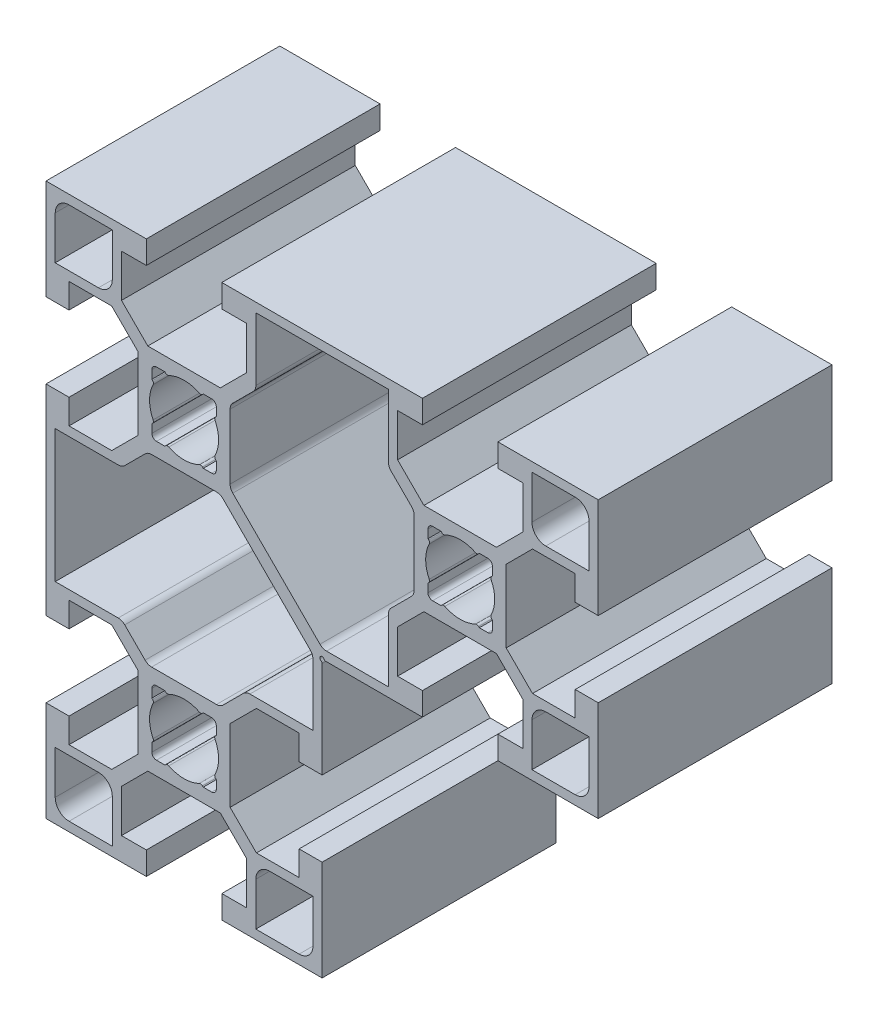
from build123d import *

# Parameters (mm, degrees)
EXTRUSION4_DEPTH = 25.4


with BuildPart() as part:
    # Sketch1 → Extrusion4 (new body)
    with BuildSketch(Plane.XY):
        with BuildLine():
            Line((-15.000000008, 14.999999985), (-4.099998488, 14.999999985))
            Line((-4.099998488, 14.999999985), (-4.099998488, 12.499999985))
            Line((-4.099998488, 12.499999985), (-6.799995438, 12.499999985))
            Line((-6.799995438, 12.499999985), (-6.799995438, 7.860655585))
            Line((-6.799995438, 7.860655585), (-3.939339838, 4.999999985))
            Line((-3.939339838, 4.999999985), (3.939339802, 4.999999985))
            Line((3.939339802, 4.999999985), (6.799995402, 7.860655585))
            Line((6.799995402, 7.860655585), (6.799995402, 12.499999985))
            Line((6.799995402, 12.499999985), (4.099998452, 12.499999985))
            Line((4.099998452, 12.499999985), (4.099998452, 14.999999985))
            Line((4.099998452, 14.999999985), (25.900001512, 14.999999985))
            Line((25.900001512, 14.999999985), (25.900001512, 12.499999985))
            Line((25.900001512, 12.499999985), (23.200004562, 12.499999985))
            Line((23.200004562, 12.499999985), (23.200004562, 7.860655585))
            Line((23.200004562, 7.860655585), (26.060660162, 4.999999985))
            Line((26.060660162, 4.999999985), (33.939339802, 4.999999985))
            Line((33.939339802, 4.999999985), (36.799995402, 7.860655585))
            Line((36.799995402, 7.860655585), (36.799995402, 12.499999985))
            Line((36.799995402, 12.499999985), (34.099998452, 12.499999985))
            Line((34.099998452, 12.499999985), (34.099998452, 14.999999985))
            Line((34.099998452, 14.999999985), (44.999999972, 14.999999985))
            Line((44.999999972, 14.999999985), (44.999999972, 4.099998475))
            Line((44.999999972, 4.099998475), (42.499999972, 4.099998475))
            Line((42.499999972, 4.099998475), (42.499999972, 6.799995425))
            Line((42.499999972, 6.799995425), (37.860655572, 6.799995425))
            Line((37.860655572, 6.799995425), (34.999999972, 3.939339825))
            Line((34.999999972, 3.939339825), (34.999999972, -3.939339815))
            Line((34.999999972, -3.939339815), (37.860655572, -6.799995415))
            Line((37.860655572, -6.799995415), (42.499999972, -6.799995415))
            Line((42.499999972, -6.799995415), (42.499999972, -4.099998465))
            Line((42.499999972, -4.099998465), (44.999999972, -4.099998465))
            Line((44.999999972, -4.099998465), (44.999999972, -14.999999985))
            Line((44.999999972, -14.999999985), (34.099998452, -14.999999985))
            Line((34.099998452, -14.999999985), (34.099998452, -12.499999985))
            Line((34.099998452, -12.499999985), (36.799995402, -12.499999985))
            Line((36.799995402, -12.499999985), (36.799995402, -7.860655585))
            Line((36.799995402, -7.860655585), (33.939339802, -4.999999985))
            Line((33.939339802, -4.999999985), (26.060660162, -4.999999985))
            Line((26.060660162, -4.999999985), (23.200004562, -7.860655585))
            Line((23.200004562, -7.860655585), (23.200004562, -12.499999985))
            Line((23.200004562, -12.499999985), (25.900001512, -12.499999985))
            Line((25.900001512, -12.499999985), (25.900001512, -14.999999985))
            Line((25.900001512, -14.999999985), (15.403112862, -14.999999985))
            ThreePointArc((15.403112862, -14.999999985), (15.297703605, -14.969967307), (15.223951582, -14.888888875))
            ThreePointArc((15.223951582, -14.888888875), (14.823223282, -14.823223295), (14.888888862, -15.223951595))
            ThreePointArc((14.888888862, -15.223951595), (14.96996729, -15.297703621), (14.999999972, -15.403112875))
            Line((14.999999972, -15.403112875), (14.999999972, -25.900001525))
            Line((14.999999972, -25.900001525), (12.499999972, -25.900001525))
            Line((12.499999972, -25.900001525), (12.499999972, -23.200004575))
            Line((12.499999972, -23.200004575), (7.860655572, -23.200004575))
            Line((7.860655572, -23.200004575), (4.999999972, -26.060660175))
            Line((4.999999972, -26.060660175), (4.999999972, -33.939339815))
            Line((4.999999972, -33.939339815), (7.860655572, -36.799995415))
            Line((7.860655572, -36.799995415), (12.499999972, -36.799995415))
            Line((12.499999972, -36.799995415), (12.499999972, -34.099998465))
            Line((12.499999972, -34.099998465), (14.999999972, -34.099998465))
            Line((14.999999972, -34.099998465), (14.999999972, -44.999999985))
            Line((14.999999972, -44.999999985), (4.099998452, -44.999999985))
            Line((4.099998452, -44.999999985), (4.099998452, -42.499999985))
            Line((4.099998452, -42.499999985), (6.799995402, -42.499999985))
            Line((6.799995402, -42.499999985), (6.799995402, -37.860655585))
            Line((6.799995402, -37.860655585), (3.939339802, -34.999999985))
            Line((3.939339802, -34.999999985), (-3.939339838, -34.999999985))
            Line((-3.939339838, -34.999999985), (-6.799995438, -37.860655585))
            Line((-6.799995438, -37.860655585), (-6.799995438, -42.499999985))
            Line((-6.799995438, -42.499999985), (-4.099998488, -42.499999985))
            Line((-4.099998488, -42.499999985), (-4.099998488, -44.999999985))
            Line((-4.099998488, -44.999999985), (-15.000000008, -44.999999985))
            Line((-15.000000008, -44.999999985), (-15.000000008, -34.099998465))
            Line((-15.000000008, -34.099998465), (-12.500000008, -34.099998465))
            Line((-12.500000008, -34.099998465), (-12.500000008, -36.799995415))
            Line((-12.500000008, -36.799995415), (-7.860655608, -36.799995415))
            Line((-7.860655608, -36.799995415), (-5.000000008, -33.939339815))
            Line((-5.000000008, -33.939339815), (-5.000000008, -26.060660175))
            Line((-5.000000008, -26.060660175), (-7.860655608, -23.200004575))
            Line((-7.860655608, -23.200004575), (-12.500000008, -23.200004575))
            Line((-12.500000008, -23.200004575), (-12.500000008, -25.900001525))
            Line((-12.500000008, -25.900001525), (-15.000000008, -25.900001525))
            Line((-15.000000008, -25.900001525), (-15.000000008, -4.099998475))
            Line((-15.000000008, -4.099998475), (-12.500000008, -4.099998475))
            Line((-12.500000008, -4.099998475), (-12.500000008, -6.799995425))
            Line((-12.500000008, -6.799995425), (-7.860655608, -6.799995425))
            Line((-7.860655608, -6.799995425), (-5.000000008, -3.939339825))
            Line((-5.000000008, -3.939339825), (-5.000000008, 3.939339815))
            Line((-5.000000008, 3.939339815), (-7.860655608, 6.799995415))
            Line((-7.860655608, 6.799995415), (-12.500000008, 6.799995415))
            Line((-12.500000008, 6.799995415), (-12.500000008, 4.099998465))
            Line((-12.500000008, 4.099998465), (-15.000000008, 4.099998465))
            Line((-15.000000008, 4.099998465), (-15.000000008, 14.999999985))
        make_face()
        with BuildLine():
            Line((-7.800000008, -39.300000005), (-7.800000008, -44.000004575))
            Line((-7.800000008, -44.000004575), (-12.500004578, -44.000004575))
            ThreePointArc((-12.500004578, -44.000004575), (-13.560664748, -43.560664745), (-14.000004578, -42.500004575))
            Line((-14.000004578, -42.500004575), (-14.000004578, -37.800000005))
            Line((-14.000004578, -37.800000005), (-9.300000008, -37.800000005))
            ThreePointArc((-9.300000008, -37.800000005), (-8.239339838, -38.239339835), (-7.800000008, -39.300000005))
        make_face(mode=Mode.SUBTRACT)
        with BuildLine():
            Line((43.999999992, 12.499999995), (43.999999992, 7.799995425))
            Line((43.999999992, 7.799995425), (39.299995422, 7.799995425))
            ThreePointArc((39.299995422, 7.799995425), (38.239335252, 8.239335255), (37.799995422, 9.299995425))
            Line((37.799995422, 9.299995425), (37.799995422, 13.999999995))
            Line((37.799995422, 13.999999995), (42.499999992, 13.999999995))
            ThreePointArc((42.499999992, 13.999999995), (43.560660162, 13.560660165), (43.999999992, 12.499999995))
        make_face(mode=Mode.SUBTRACT)
        with BuildLine():
            Line((9.299999992, -37.800000005), (14.000004562, -37.800000005))
            Line((14.000004562, -37.800000005), (14.000004562, -42.500004575))
            ThreePointArc((14.000004562, -42.500004575), (13.560664732, -43.560664745), (12.500004562, -44.000004575))
            Line((12.500004562, -44.000004575), (7.799999992, -44.000004575))
            Line((7.799999992, -44.000004575), (7.799999992, -39.300000005))
            ThreePointArc((7.799999992, -39.300000005), (8.239339822, -38.239339835), (9.299999992, -37.800000005))
        make_face(mode=Mode.SUBTRACT)
        with BuildLine():
            Line((39.299999992, -7.800000005), (44.000004562, -7.800000005))
            Line((44.000004562, -7.800000005), (44.000004562, -12.500004575))
            ThreePointArc((44.000004562, -12.500004575), (43.560664732, -13.560664745), (42.500004562, -14.000004575))
            Line((42.500004562, -14.000004575), (37.799999992, -14.000004575))
            Line((37.799999992, -14.000004575), (37.799999992, -9.300000005))
            ThreePointArc((37.799999992, -9.300000005), (38.239339822, -8.239339835), (39.299999992, -7.800000005))
        make_face(mode=Mode.SUBTRACT)
        with BuildLine():
            Line((-12.500000008, 13.999999995), (-7.799995438, 13.999999995))
            Line((-7.799995438, 13.999999995), (-7.799995438, 9.299995425))
            ThreePointArc((-7.799995438, 9.299995425), (-8.239335268, 8.239335255), (-9.299995438, 7.799995425))
            Line((-9.299995438, 7.799995425), (-14.000000008, 7.799995425))
            Line((-14.000000008, 7.799995425), (-14.000000008, 12.499999995))
            ThreePointArc((-14.000000008, 12.499999995), (-13.560660178, 13.560660165), (-12.500000008, 13.999999995))
        make_face(mode=Mode.SUBTRACT)
        with BuildLine():
            Line((32.005133972, 3.419347545), (32.085786412, 3.499999985))
            Line((32.085786412, 3.499999985), (32.999999972, 3.499999985))
            ThreePointArc((32.999999972, 3.499999985), (33.353553362, 3.353553375), (33.499999972, 2.999999985))
            Line((33.499999972, 2.999999985), (33.499999972, 2.085786425))
            Line((33.499999972, 2.085786425), (33.419347532, 2.005133985))
            ThreePointArc((33.419347532, 2.005133985), (33.335474922, 1.841799984), (33.362481082, 1.660186995))
            ThreePointArc((33.362481082, 1.660186995), (33.749999978, -1e-09), (33.362481082, -1.660186995))
            ThreePointArc((33.362481082, -1.660186995), (33.335474922, -1.841799984), (33.419347532, -2.005133985))
            Line((33.419347532, -2.005133985), (33.499999972, -2.085786425))
            Line((33.499999972, -2.085786425), (33.499999972, -2.999999985))
            ThreePointArc((33.499999972, -2.999999985), (33.353553362, -3.353553375), (32.999999972, -3.499999985))
            Line((32.999999972, -3.499999985), (32.085786412, -3.499999985))
            Line((32.085786412, -3.499999985), (32.005133972, -3.419347545))
            ThreePointArc((32.005133972, -3.419347545), (31.841799971, -3.335474935), (31.660186982, -3.362481095))
            ThreePointArc((31.660186982, -3.362481095), (29.999999987, -3.749999998), (28.339812992, -3.362481095))
            ThreePointArc((28.339812992, -3.362481095), (28.158200003, -3.335474935), (27.994866002, -3.419347545))
            Line((27.994866002, -3.419347545), (27.914213562, -3.499999985))
            Line((27.914213562, -3.499999985), (27.000000002, -3.499999985))
            ThreePointArc((27.000000002, -3.499999985), (26.646446612, -3.353553375), (26.500000002, -2.999999985))
            Line((26.500000002, -2.999999985), (26.500000002, -2.085786425))
            Line((26.500000002, -2.085786425), (26.580652442, -2.005133985))
            ThreePointArc((26.580652442, -2.005133985), (26.664525052, -1.841799984), (26.637518892, -1.660186995))
            ThreePointArc((26.637518892, -1.660186995), (26.249999985, -1e-09), (26.637518892, 1.660186995))
            ThreePointArc((26.637518892, 1.660186995), (26.664525052, 1.841799984), (26.580652442, 2.005133985))
            Line((26.580652442, 2.005133985), (26.500000002, 2.085786425))
            Line((26.500000002, 2.085786425), (26.500000002, 2.999999985))
            ThreePointArc((26.500000002, 2.999999985), (26.646446612, 3.353553375), (27.000000002, 3.499999985))
            Line((27.000000002, 3.499999985), (27.914213562, 3.499999985))
            Line((27.914213562, 3.499999985), (27.994866002, 3.419347545))
            ThreePointArc((27.994866002, 3.419347545), (28.158200003, 3.335474935), (28.339812992, 3.362481095))
            ThreePointArc((28.339812992, 3.362481095), (29.999999987, 3.749999995), (31.660186982, 3.362481095))
            ThreePointArc((31.660186982, 3.362481095), (31.841799971, 3.335474935), (32.005133972, 3.419347545))
        make_face(mode=Mode.SUBTRACT)
        with BuildLine():
            Line((2.005133972, -26.580652455), (2.085786412, -26.500000015))
            Line((2.085786412, -26.500000015), (2.999999972, -26.500000015))
            ThreePointArc((2.999999972, -26.500000015), (3.353553362, -26.646446625), (3.499999972, -27.000000015))
            Line((3.499999972, -27.000000015), (3.499999972, -27.914213575))
            Line((3.499999972, -27.914213575), (3.419347532, -27.994866015))
            ThreePointArc((3.419347532, -27.994866015), (3.335474922, -28.158200016), (3.362481082, -28.339813005))
            ThreePointArc((3.362481082, -28.339813005), (3.749999978, -30.000000001), (3.362481082, -31.660186995))
            ThreePointArc((3.362481082, -31.660186995), (3.335474922, -31.841799984), (3.419347532, -32.005133985))
            Line((3.419347532, -32.005133985), (3.499999972, -32.085786425))
            Line((3.499999972, -32.085786425), (3.499999972, -32.999999985))
            ThreePointArc((3.499999972, -32.999999985), (3.353553362, -33.353553375), (2.999999972, -33.499999985))
            Line((2.999999972, -33.499999985), (2.085786412, -33.499999985))
            Line((2.085786412, -33.499999985), (2.005133972, -33.419347545))
            ThreePointArc((2.005133972, -33.419347545), (1.841799971, -33.335474935), (1.660186982, -33.362481095))
            ThreePointArc((1.660186982, -33.362481095), (-1.3e-08, -33.749999998), (-1.660187008, -33.362481095))
            ThreePointArc((-1.660187008, -33.362481095), (-1.841799997, -33.335474935), (-2.005133998, -33.419347545))
            Line((-2.005133998, -33.419347545), (-2.085786438, -33.499999985))
            Line((-2.085786438, -33.499999985), (-2.999999998, -33.499999985))
            ThreePointArc((-2.999999998, -33.499999985), (-3.353553388, -33.353553375), (-3.499999998, -32.999999985))
            Line((-3.499999998, -32.999999985), (-3.499999998, -32.085786425))
            Line((-3.499999998, -32.085786425), (-3.419347558, -32.005133985))
            ThreePointArc((-3.419347558, -32.005133985), (-3.335474948, -31.841799984), (-3.362481108, -31.660186995))
            ThreePointArc((-3.362481108, -31.660186995), (-3.750000015, -30.000000001), (-3.362481108, -28.339813005))
            ThreePointArc((-3.362481108, -28.339813005), (-3.335474948, -28.158200016), (-3.419347558, -27.994866015))
            Line((-3.419347558, -27.994866015), (-3.499999998, -27.914213575))
            Line((-3.499999998, -27.914213575), (-3.499999998, -27.000000015))
            ThreePointArc((-3.499999998, -27.000000015), (-3.353553388, -26.646446625), (-2.999999998, -26.500000015))
            Line((-2.999999998, -26.500000015), (-2.085786438, -26.500000015))
            Line((-2.085786438, -26.500000015), (-2.005133998, -26.580652455))
            ThreePointArc((-2.005133998, -26.580652455), (-1.841799997, -26.664525065), (-1.660187008, -26.637518905))
            ThreePointArc((-1.660187008, -26.637518905), (-1.3e-08, -26.250000005), (1.660186982, -26.637518905))
            ThreePointArc((1.660186982, -26.637518905), (1.841799971, -26.664525065), (2.005133972, -26.580652455))
        make_face(mode=Mode.SUBTRACT)
        with BuildLine():
            Line((2.005133972, 3.419347545), (2.085786412, 3.499999985))
            Line((2.085786412, 3.499999985), (2.999999972, 3.499999985))
            ThreePointArc((2.999999972, 3.499999985), (3.353553362, 3.353553375), (3.499999972, 2.999999985))
            Line((3.499999972, 2.999999985), (3.499999972, 2.085786425))
            Line((3.499999972, 2.085786425), (3.419347532, 2.005133985))
            ThreePointArc((3.419347532, 2.005133985), (3.335474922, 1.841799984), (3.362481082, 1.660186995))
            ThreePointArc((3.362481082, 1.660186995), (3.749999978, -1e-09), (3.362481082, -1.660186995))
            ThreePointArc((3.362481082, -1.660186995), (3.335474922, -1.841799984), (3.419347532, -2.005133985))
            Line((3.419347532, -2.005133985), (3.499999972, -2.085786425))
            Line((3.499999972, -2.085786425), (3.499999972, -2.999999985))
            ThreePointArc((3.499999972, -2.999999985), (3.353553362, -3.353553375), (2.999999972, -3.499999985))
            Line((2.999999972, -3.499999985), (2.085786412, -3.499999985))
            Line((2.085786412, -3.499999985), (2.005133972, -3.419347545))
            ThreePointArc((2.005133972, -3.419347545), (1.841799971, -3.335474935), (1.660186982, -3.362481095))
            ThreePointArc((1.660186982, -3.362481095), (-1.3e-08, -3.749999998), (-1.660187008, -3.362481095))
            ThreePointArc((-1.660187008, -3.362481095), (-1.841799997, -3.335474935), (-2.005133998, -3.419347545))
            Line((-2.005133998, -3.419347545), (-2.085786438, -3.499999985))
            Line((-2.085786438, -3.499999985), (-2.999999998, -3.499999985))
            ThreePointArc((-2.999999998, -3.499999985), (-3.353553388, -3.353553375), (-3.499999998, -2.999999985))
            Line((-3.499999998, -2.999999985), (-3.499999998, -2.085786425))
            Line((-3.499999998, -2.085786425), (-3.419347558, -2.005133985))
            ThreePointArc((-3.419347558, -2.005133985), (-3.335474948, -1.841799984), (-3.362481108, -1.660186995))
            ThreePointArc((-3.362481108, -1.660186995), (-3.750000015, -1e-09), (-3.362481108, 1.660186995))
            ThreePointArc((-3.362481108, 1.660186995), (-3.335474948, 1.841799984), (-3.419347558, 2.005133985))
            Line((-3.419347558, 2.005133985), (-3.499999998, 2.085786425))
            Line((-3.499999998, 2.085786425), (-3.499999998, 2.999999985))
            ThreePointArc((-3.499999998, 2.999999985), (-3.353553388, 3.353553375), (-2.999999998, 3.499999985))
            Line((-2.999999998, 3.499999985), (-2.085786438, 3.499999985))
            Line((-2.085786438, 3.499999985), (-2.005133998, 3.419347545))
            ThreePointArc((-2.005133998, 3.419347545), (-1.841799997, 3.335474935), (-1.660187008, 3.362481095))
            ThreePointArc((-1.660187008, 3.362481095), (-1.3e-08, 3.749999995), (1.660186982, 3.362481095))
            ThreePointArc((1.660186982, 3.362481095), (1.841799971, 3.335474935), (2.005133972, 3.419347545))
        make_face(mode=Mode.SUBTRACT)
        with BuildLine():
            Line((-3.525126258, -4.999999995), (3.525126252, -4.999999995))
            ThreePointArc((3.525126252, -4.999999995), (3.907809683, -5.076120465), (4.232233032, -5.292893215))
            Line((4.232233032, -5.292893215), (13.707106762, -14.767766945))
            ThreePointArc((13.707106762, -14.767766945), (13.923879512, -15.092190294), (13.999999982, -15.474873725))
            Line((13.999999982, -15.474873725), (13.999999982, -22.200004585))
            Line((13.999999982, -22.200004585), (7.153548802, -22.200004585))
            ThreePointArc((7.153548802, -22.200004585), (6.770865371, -22.276125055), (6.446442022, -22.492897805))
            Line((6.446442022, -22.492897805), (4.232233032, -24.707106795))
            ThreePointArc((4.232233032, -24.707106795), (3.907809683, -24.923879545), (3.525126252, -25.000000015))
            Line((3.525126252, -25.000000015), (-3.525126258, -25.000000015))
            ThreePointArc((-3.525126258, -25.000000015), (-3.907809689, -24.923879545), (-4.232233038, -24.707106795))
            Line((-4.232233038, -24.707106795), (-6.446442028, -22.492897805))
            ThreePointArc((-6.446442028, -22.492897805), (-6.770865377, -22.276125055), (-7.153548808, -22.200004585))
            Line((-7.153548808, -22.200004585), (-13.999999988, -22.200004585))
            Line((-13.999999988, -22.200004585), (-13.999999988, -7.799995425))
            Line((-13.999999988, -7.799995425), (-7.153548808, -7.799995425))
            ThreePointArc((-7.153548808, -7.799995425), (-6.770865377, -7.723874955), (-6.446442028, -7.507102205))
            Line((-6.446442028, -7.507102205), (-4.232233038, -5.292893215))
            ThreePointArc((-4.232233038, -5.292893215), (-3.907809689, -5.076120465), (-3.525126258, -4.999999995))
        make_face(mode=Mode.SUBTRACT)
        with BuildLine():
            Line((5.292893202, 4.232233025), (7.507102192, 6.446442015))
            ThreePointArc((7.507102192, 6.446442015), (7.723874942, 6.770865364), (7.799995412, 7.153548795))
            Line((7.799995412, 7.153548795), (7.799995412, 13.999999975))
            Line((7.799995412, 13.999999975), (22.200004572, 13.999999975))
            Line((22.200004572, 13.999999975), (22.200004572, 7.153548795))
            ThreePointArc((22.200004572, 7.153548795), (22.276125042, 6.770865364), (22.492897792, 6.446442015))
            Line((22.492897792, 6.446442015), (24.707106782, 4.232233025))
            ThreePointArc((24.707106782, 4.232233025), (24.923879532, 3.907809676), (25.000000002, 3.525126245))
            Line((25.000000002, 3.525126245), (25.000000002, -3.525126265))
            ThreePointArc((25.000000002, -3.525126265), (24.923879532, -3.907809696), (24.707106782, -4.232233045))
            Line((24.707106782, -4.232233045), (22.492897792, -6.446442035))
            ThreePointArc((22.492897792, -6.446442035), (22.276125042, -6.770865384), (22.200004572, -7.153548815))
            Line((22.200004572, -7.153548815), (22.200004572, -13.999999995))
            Line((22.200004572, -13.999999995), (15.474873712, -13.999999995))
            ThreePointArc((15.474873712, -13.999999995), (15.092190281, -13.923879525), (14.767766932, -13.707106775))
            Line((14.767766932, -13.707106775), (5.292893202, -4.232233045))
            ThreePointArc((5.292893202, -4.232233045), (5.076120452, -3.907809696), (4.999999982, -3.525126265))
            Line((4.999999982, -3.525126265), (4.999999982, 3.525126245))
            ThreePointArc((4.999999982, 3.525126245), (5.076120452, 3.907809676), (5.292893202, 4.232233025))
        make_face(mode=Mode.SUBTRACT)
    extrude(amount=EXTRUSION4_DEPTH)


solid = part.part
